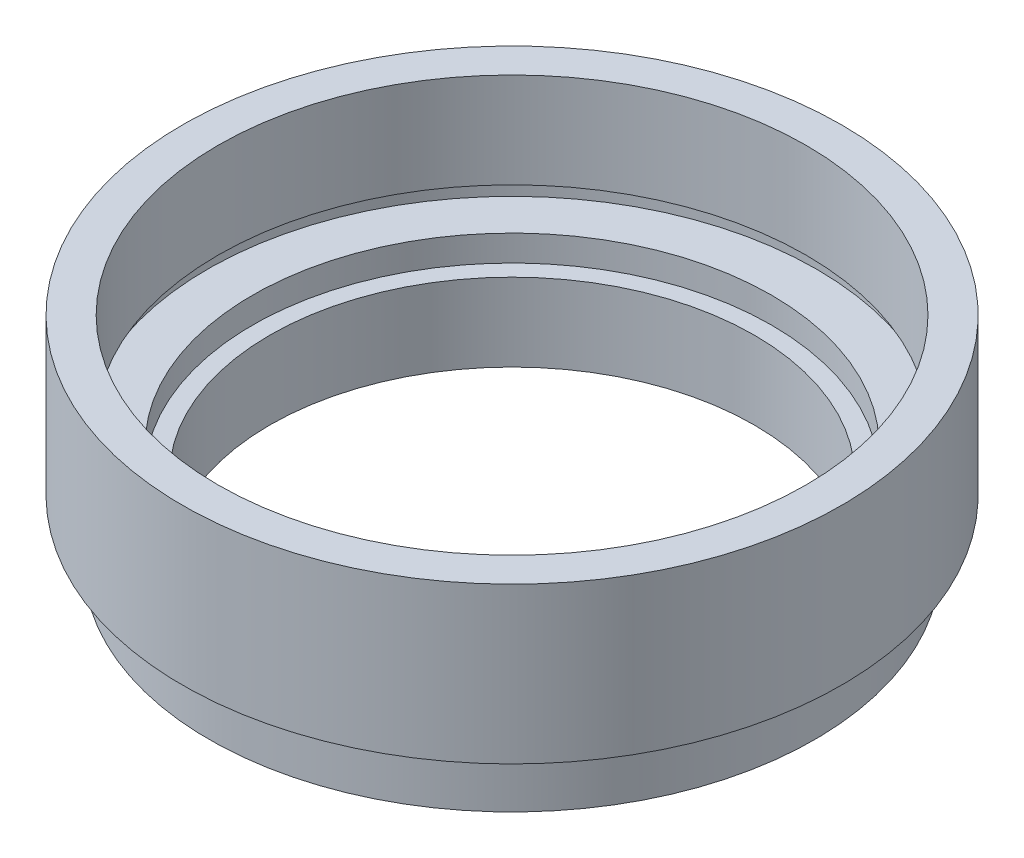
from build123d import *


with BuildPart() as part:
    # 草图1 → 旋转1 (revolve)
    with BuildSketch(Plane.XY, mode=Mode.PRIVATE) as revolve_1_sk:
        Polygon((14, 0), (17.5, 0), (17.5, 2.5), (17, 2.5), (17, 3.5), (19.05, 3.5), (19.05, 12.5), (17, 12.5), (17, 7), (17.6, 7), (17.6, 6), (15, 6), (15, 4.5), (14, 4.5), align=None)
    revolve(revolve_1_sk.sketch.rotate(Axis((0, 0, 0), (0, 1, 0)), 90), axis=Axis((0, 0, 0), (0, 1, 0)))  # turned: the seam where the file's is


solid = part.part
